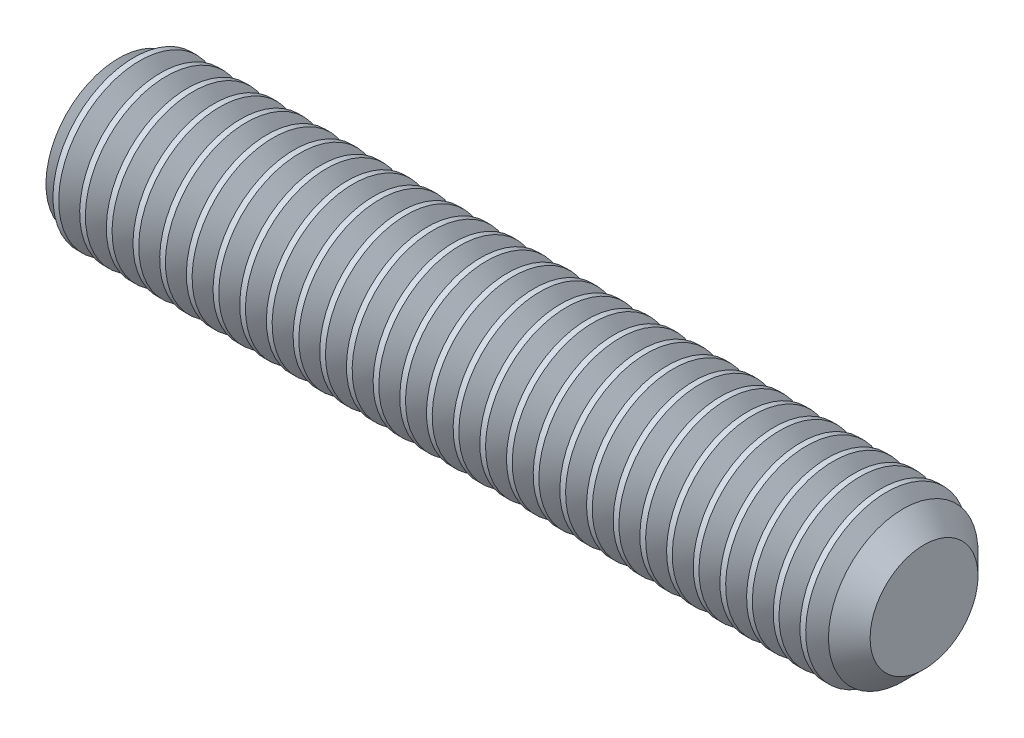
from build123d import *

# Parameters (mm, degrees)
HEX_2_DEPTH     = 3.5
THDSCHPAT_COUNT = 30
THDSCHPAT_PITCH = 0.988960665


with BuildPart() as part:
    # BodySke → BaseBody (revolve)
    with BuildSketch(Plane.XY):
        Polygon((0, 0), (0, 2.4455), (0.320140724, 3), (29, 3), (30, 2), (30, 0), align=None)
    revolve(axis=Axis((-12.7, 0, 0), (1, 0, 0)))

    # Sketch2 → Hex 2 (cut)
    with BuildSketch(Plane.ZY):
        Polygon((0.866025404, 1.5), (-0.866025404, 1.5), (-1.732050808, 0), (-0.866025404, -1.5), (0.866025404, -1.5), (1.732050808, 0), align=None)
    extrude(amount=-HEX_2_DEPTH, mode=Mode.SUBTRACT)

    # ThdSchSke → ThreadSchematic (revolve, cut)
    with BuildSketch(Plane.XY):
        Polygon((0.320140724, -2.4455), (-0.068124356, -3), (-0.068124356, -3.75), (0.708405804, -3.75), (0.708405804, -3), align=None)
    threadschematic = revolve(axis=Axis((-3.175, 0, 0), (1, 0, 0)), mode=Mode.SUBTRACT)

    # ThdSchPat: ThreadSchematic ×30
    with Locations(*[(i * THDSCHPAT_PITCH, 0, 0) for i in range(1, THDSCHPAT_COUNT)]):
        add(threadschematic, mode=Mode.SUBTRACT)


solid = part.part
